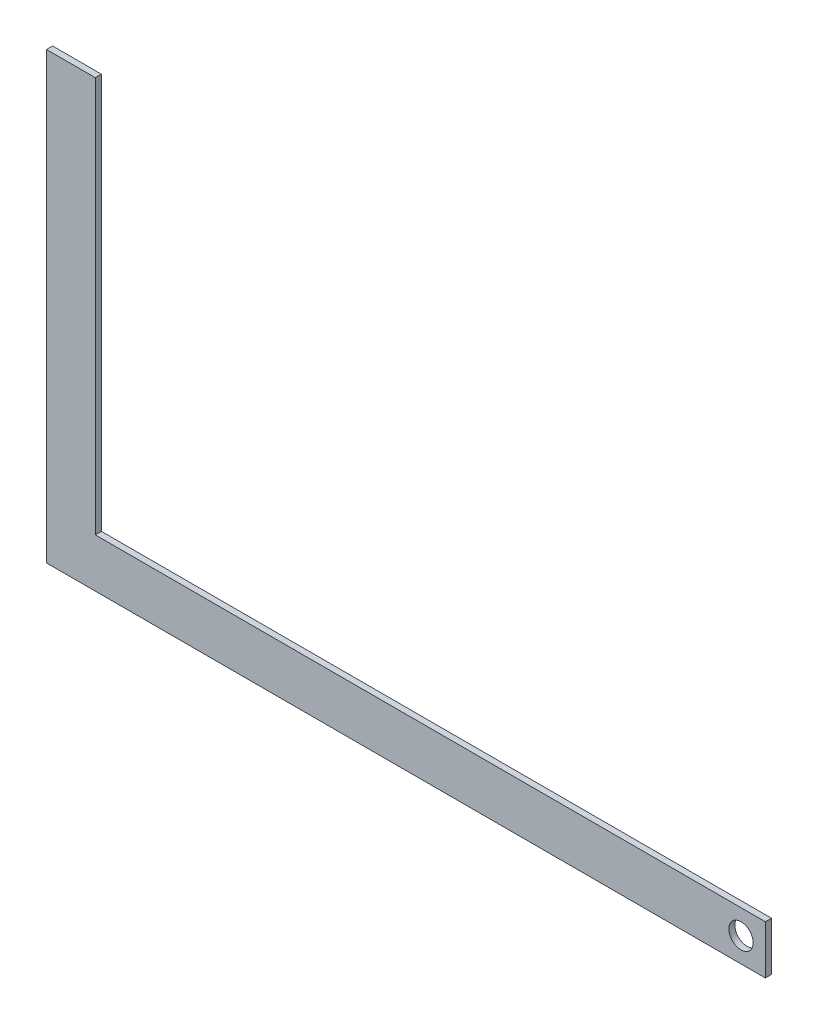
from build123d import *

# Parameters (mm, degrees)
SKETCH1_W           = 374.65
SKETCH1_H           = 25.4
SKETCH1_R           = 6.35
BOSS_EXTRUDE1_DEPTH = 3.175
SKETCH2_W           = 25.4
SKETCH2_H           = 206.375
BOSS_EXTRUDE2_DEPTH = 3.175


with BuildPart() as part:
    # Sketch1 → Boss-Extrude1 (new body)
    with BuildSketch(Plane.XY):
        with Locations((187.325, 12.7)):
            Rectangle(SKETCH1_W, SKETCH1_H)
        with Locations((361.95, 12.7)):
            Circle(SKETCH1_R, mode=Mode.SUBTRACT)
    extrude(amount=BOSS_EXTRUDE1_DEPTH)

    # Sketch2 → Boss-Extrude2 (add)
    with BuildSketch(Plane.XY.offset(3.175)):
        with Locations((12.7, 128.5875)):
            Rectangle(SKETCH2_W, SKETCH2_H)
    extrude(amount=-BOSS_EXTRUDE2_DEPTH)


solid = part.part
